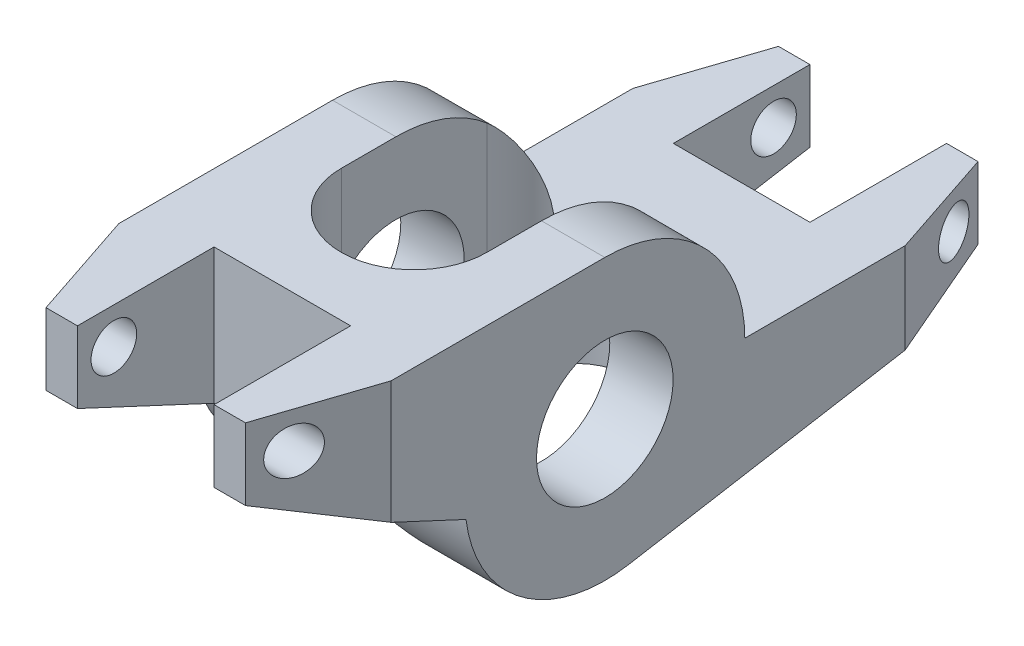
from build123d import *

# Parameters (mm, degrees)
SKETCH1_R             = 4.765
BOSS_EXTRUDE1_DEPTH   = 9.5
CHAMFER1_SIZE         = 2.54
CHAMFER1_SIZE2        = 7.62
CHAMFER1_PART_2_SIZE  = 2.54
CHAMFER1_PART_2_SIZE2 = 7.62
CHAMFER2_SIZE         = 7.62
CHAMFER2_SIZE2        = 2.54
CUT_EXTRUDE1_DEPTH    = 17
SKETCH3_W             = 9.53
SKETCH3_H             = 9.53
CUT_EXTRUDE2_DEPTH    = 17
SKETCH4_R             = 1.59
CUT_EXTRUDE3_DEPTH    = 17


with BuildPart() as part:
    # Sketch1 → Boss-Extrude1 (new body, symmetric)
    with BuildSketch(Plane(origin=(0, 0, 0), x_dir=(0, 0, -1), z_dir=(1, 0, 0))):
        with BuildLine():
            Line((0, 9.765), (-22.53, 9.765))
            Line((-22.53, 9.765), (-22.53, 4.765))
            Line((-22.53, 4.765), (-9.688074689, -1.223288118))
            ThreePointArc((-9.688074689, -1.223288118), (-5.812387316, -7.84674319), (1.653013564, -9.624072483))
            Line((1.653013564, -9.624072483), (28.575, -5))
            Line((28.575, -5), (28.575, 0))
            Line((28.575, 0), (9.765, 0))
            ThreePointArc((9.765, 0), (6.904897718, 6.904897718), (0, 9.765))
        make_face()
        Circle(SKETCH1_R, mode=Mode.SUBTRACT)
    extrude(amount=BOSS_EXTRUDE1_DEPTH, both=True)

    # Chamfer1
    chamfer1_edges = [part.edges().sort_by_distance(p)[0] for p in [
        (9.5, 7.265, 22.53),
    ]]
    chamfer1_side = [part.faces().sort_by_distance(p)[0] for p in [
        (0, 7.265, 22.53),
    ]]
    chamfer(chamfer1_edges, length=CHAMFER1_SIZE, length2=CHAMFER1_SIZE2, reference=chamfer1_side[0])

    # Chamfer1 part 2
    chamfer1_part_2_edges = [part.edges().sort_by_distance(p)[0] for p in [
        (9.5, -2.5, -28.575),
    ]]
    chamfer1_part_2_side = [part.faces().sort_by_distance(p)[0] for p in [
        (0, -2.5, -28.575),
    ]]
    chamfer(chamfer1_part_2_edges, length=CHAMFER1_PART_2_SIZE, length2=CHAMFER1_PART_2_SIZE2, reference=chamfer1_part_2_side[0])

    # Chamfer2
    chamfer2_edges = [part.edges().sort_by_distance(p)[0] for p in [
        (-9.5, 7.265, 22.53),
        (-9.5, -2.5, -28.575),
    ]]
    chamfer2_side = [part.faces().sort_by_distance(p)[0] for p in [
        (-9.5, 9.217903854, 11.265),
    ]]
    chamfer(chamfer2_edges, length=CHAMFER2_SIZE, length2=CHAMFER2_SIZE2, reference=chamfer2_side[0])

    # Sketch2 → Cut-Extrude1 (cut, symmetric)
    with BuildSketch(Plane(origin=(0, 0, 0), x_dir=(1, 0, 0), z_dir=(0, 1, 0))):
        with BuildLine():
            Line((5.08, 6.35), (5.08, -3.81))
            ThreePointArc((5.08, -3.81), (0, -8.89), (-5.08, -3.81))
            Line((-5.08, -3.81), (-5.08, 6.35))
            ThreePointArc((-5.08, 6.35), (0, 11.43), (5.08, 6.35))
        make_face()
    extrude(amount=CUT_EXTRUDE1_DEPTH, both=True, mode=Mode.SUBTRACT)

    # Sketch3 → Cut-Extrude2 (cut, symmetric)
    with BuildSketch(Plane(origin=(0, 0, 0), x_dir=(1, 0, 0), z_dir=(0, 1, 0))):
        with Locations((0, 23.81)):
            Rectangle(SKETCH3_W, SKETCH3_H)
        with Locations((0, -17.765)):
            Rectangle(SKETCH3_W, SKETCH3_H)
    extrude(amount=CUT_EXTRUDE2_DEPTH, both=True, mode=Mode.SUBTRACT)

    # Sketch4 → Cut-Extrude3 (cut, symmetric)
    with BuildSketch(Plane(origin=(0, 0, 0), x_dir=(0, 0, -1), z_dir=(1, 0, 0))):
        with Locations((26.035, -2.54)):
            Circle(SKETCH4_R)
        with Locations((-19.99, 7.225)):
            Circle(SKETCH4_R)
    extrude(amount=CUT_EXTRUDE3_DEPTH, both=True, mode=Mode.SUBTRACT)


solid = part.part
